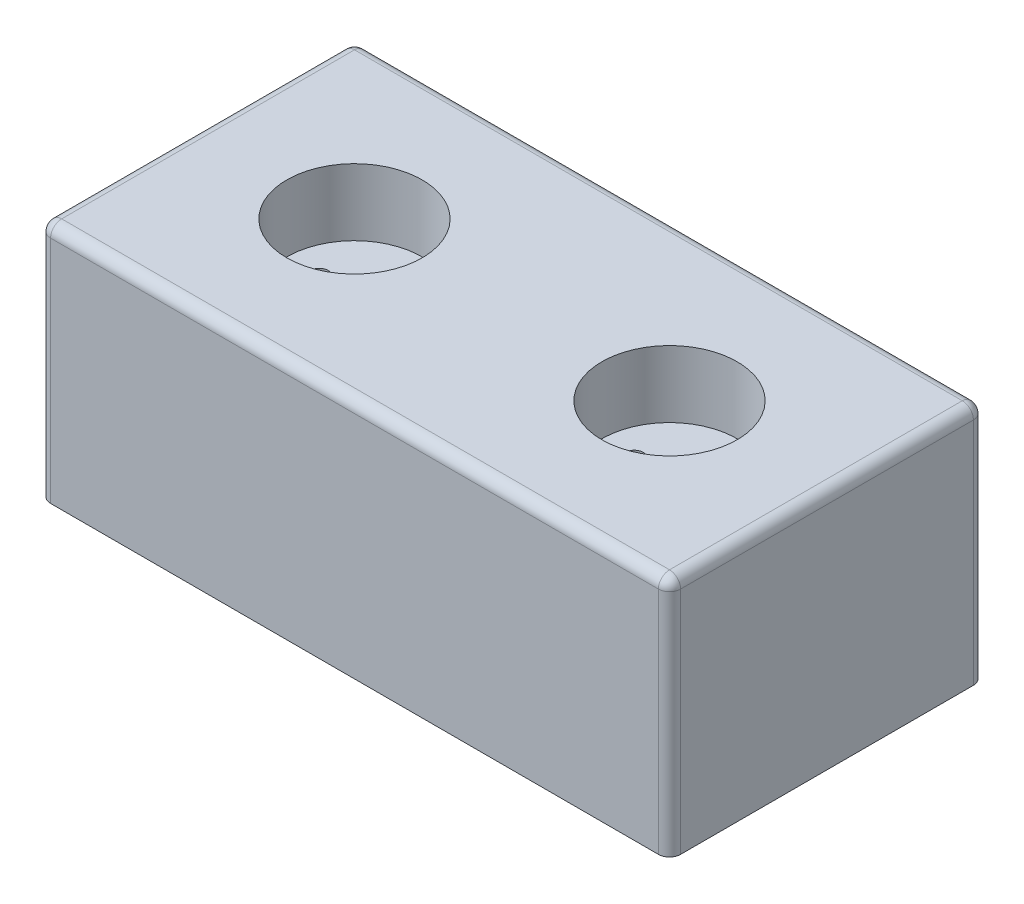
from build123d import *

# Parameters (mm, degrees)
SKETCH_1_W          = 170
SKETCH_1_H          = 85
EXTRUDE_1_DEPTH     = 65
SKETCH_2_R          = 18.25
CUT_EXTRUDE_1_DEPTH = 18
SKETCH_3_R          = 2.4
CUT_EXTRUDE_2_DEPTH = 15
FILLET_1_R          = 3


with BuildPart() as part:
    # Эскиз1 → Бобышка-Вытянуть1 (new body)
    with BuildSketch(Plane(origin=(0, 0, 0), x_dir=(1, 0, 0), z_dir=(0, 1, 0))):
        Rectangle(SKETCH_1_W, SKETCH_1_H)
    extrude(amount=EXTRUDE_1_DEPTH)

    # Эскиз2 → Вырез-Вытянуть1 (cut)
    with BuildSketch(Plane(origin=(0, 65, 0), x_dir=(1, 0, 0), z_dir=(0, 1, 0))):
        with Locations((-42.5, 0)):
            Circle(SKETCH_2_R)
        with Locations((42.5, 0)):
            Circle(SKETCH_2_R)
    extrude(amount=-CUT_EXTRUDE_1_DEPTH, mode=Mode.SUBTRACT)

    # Эскиз3 → Вырез-Вытянуть2 (cut)
    with BuildSketch(Plane(origin=(0, 47, 0), x_dir=(1, 0, 0), z_dir=(0, 1, 0))):
        with Locations((-52, 0)):
            Circle(SKETCH_3_R)
        with Locations((-33, 0)):
            Circle(SKETCH_3_R)
        with Locations((33, 0)):
            Circle(SKETCH_3_R)
        with Locations((52, 0)):
            Circle(SKETCH_3_R)
    extrude(amount=-CUT_EXTRUDE_2_DEPTH, mode=Mode.SUBTRACT)

    # Скругление1
    fillet_1_edges = [part.edges().sort_by_distance(p)[0] for p in [
        (85, 65, 0),
        (0, 65, -42.5),
        (-85, 65, 0),
        (0, 65, 42.5),
        (-85, 32.5, -42.5),
        (85, 32.5, -42.5),
        (85, 32.5, 42.5),
        (-85, 32.5, 42.5),
    ]]
    fillet(fillet_1_edges, radius=FILLET_1_R)


solid = part.part
